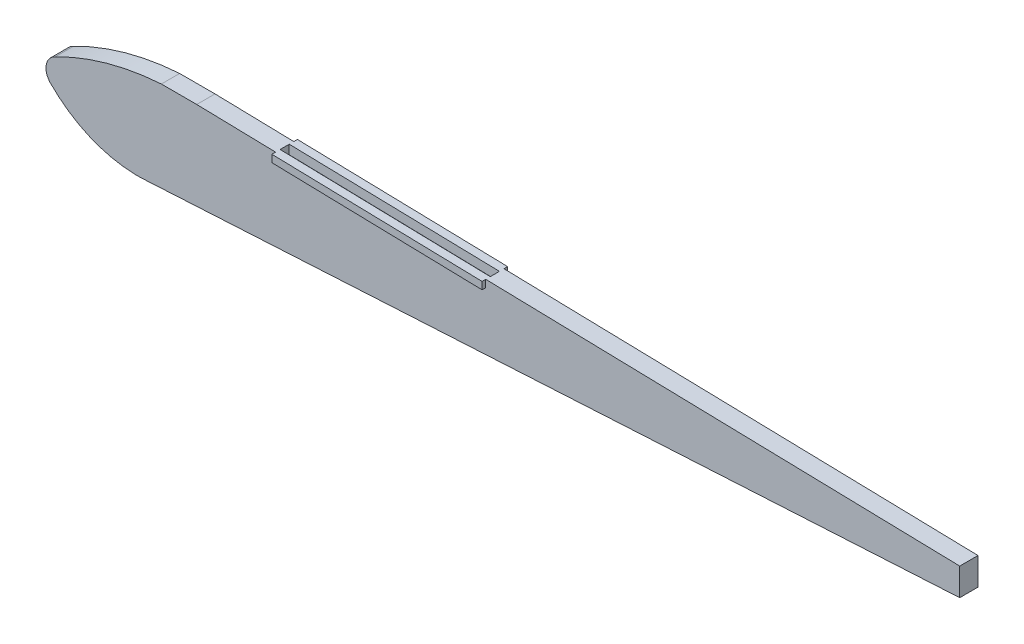
from build123d import *

# Parameters (mm, degrees)
SKETCH1_W                = 500
SKETCH1_H                = 50
BOSS_EXTRUDE1_DEPTH      = 10
CUT_EXTRUDE1_DEPTH       = 11
BOSS_EXTRUDE3_DEPTH      = 2
BOSS_EXTRUDE3_DEPTH_BACK = 12
SKETCH4_W                = 115.032991515
SKETCH4_H                = 5
CUT_EXTRUDE2_DEPTH       = 5


with BuildPart() as part:
    # Sketch1 → Boss-Extrude1 (new body)
    with BuildSketch(Plane.XY):
        with Locations((283.352405613, 0)):
            Rectangle(SKETCH1_W, SKETCH1_H)
    extrude(amount=BOSS_EXTRUDE1_DEPTH)

    # Sketch2 → Cut-Extrude1 (cut, through all)
    with BuildSketch(Plane.XY.offset(10)):
        Polygon((533.352405613, 0), (85.627765445, -25), (533.352405613, -25), align=None)
        with BuildLine():
            Line((33.352405613, -25), (81.993040664, -25))
            ThreePointArc((81.993040664, -25), (56.907700084, -19.408398641), (35.752423976, -4.814063764))
            ThreePointArc((35.752423976, -4.814063764), (33.571532765, 2.680644565), (38.404725068, 8.809852636))
            ThreePointArc((38.404725068, 8.809852636), (66.634144242, 19.90850289), (96.536599016, 25))
            Line((96.536599016, 25), (33.352405613, 25))
            Line((33.352405613, 25), (33.352405613, -25))
        make_face()
        Polygon((115.905115224, 25), (533.352405613, 15), (533.352405613, 25), align=None)
    extrude(amount=-CUT_EXTRUDE1_DEPTH, mode=Mode.SUBTRACT)

    # Sketch3 → Boss-Extrude3 (add, two sides)
    with BuildSketch(Plane(origin=(0, 0, 0), x_dir=(-1, 0, 0), z_dir=(0, 0, -1))) as boss_extrude3_sk:
        Polygon((-159.0031787, 23.967580711), (-274.0031787, 21.212741893), (-274.0031787, 17.212741893), (-159.0031787, 19.967580711), align=None)
    extrude(amount=BOSS_EXTRUDE3_DEPTH)
    extrude(boss_extrude3_sk.sketch, amount=-BOSS_EXTRUDE3_DEPTH_BACK)

    # Sketch4 → Cut-Extrude2 (cut)
    with BuildSketch(Plane(origin=(0.665008284, 27.760590609, 0), x_dir=(0.9997132, -0.02394825, 0), z_dir=(0.02394825, 0.9997132, 0))):
        with Locations((215.900090662, -5)):
            Rectangle(SKETCH4_W, SKETCH4_H)
    extrude(amount=-CUT_EXTRUDE2_DEPTH, mode=Mode.SUBTRACT)


solid = part.part
